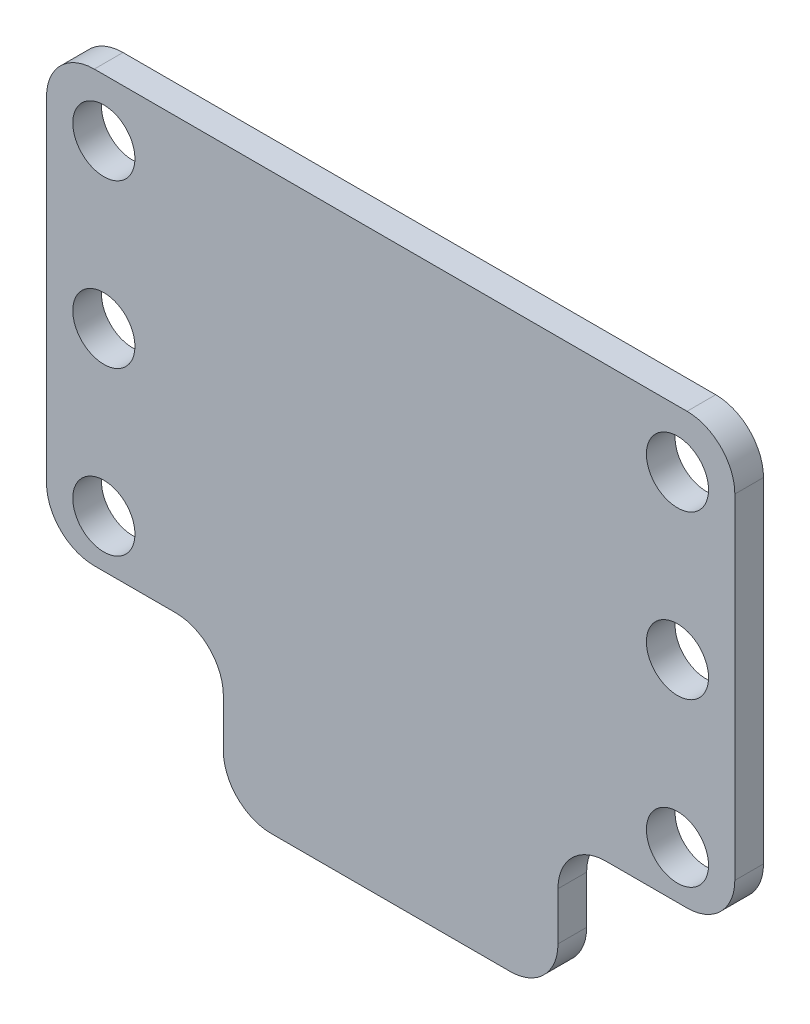
from build123d import *

# Parameters (mm, degrees)
ESQUISSE2_R        = 3.25
BOSS_EXTRU_1_DEPTH = 3
CONG_1_R           = 5


with BuildPart() as part:
    # Esquisse2 → Boss.-Extru.1 (new body)
    with BuildSketch(Plane.XY):
        Polygon((109.208492459, 1.901473412), (37.208492459, 1.901473412), (37.208492459, -43.098526588), (55.708492459, -43.098526588), (55.708492459, -58.098526588), (90.708492459, -58.098526588), (90.708492459, -43.098526588), (109.208492459, -43.098526588), align=None)
        with Locations((103.208492459, -4.098526588)):
            Circle(ESQUISSE2_R, mode=Mode.SUBTRACT)
        with Locations((103.208492459, -38.098526588)):
            Circle(ESQUISSE2_R, mode=Mode.SUBTRACT)
        with Locations((43.208492459, -38.098526588)):
            Circle(ESQUISSE2_R, mode=Mode.SUBTRACT)
        with Locations((43.208492459, -4.098526588)):
            Circle(ESQUISSE2_R, mode=Mode.SUBTRACT)
        with Locations((43.208492459, -21.098526588)):
            Circle(ESQUISSE2_R, mode=Mode.SUBTRACT)
        with Locations((103.208492459, -21.098526588)):
            Circle(ESQUISSE2_R, mode=Mode.SUBTRACT)
    extrude(amount=BOSS_EXTRU_1_DEPTH)

    # Congé1
    cong_1_edges = [part.edges().sort_by_distance(p)[0] for p in [
        (109.208492459, -43.098526588, 1.5),
        (90.708492459, -43.098526588, 1.5),
        (90.708492459, -58.098526588, 1.5),
        (55.708492459, -58.098526588, 1.5),
        (55.708492459, -43.098526588, 1.5),
        (37.208492459, -43.098526588, 1.5),
        (37.208492459, 1.901473412, 1.5),
        (109.208492459, 1.901473412, 1.5),
    ]]
    fillet(cong_1_edges, radius=CONG_1_R)


solid = part.part
